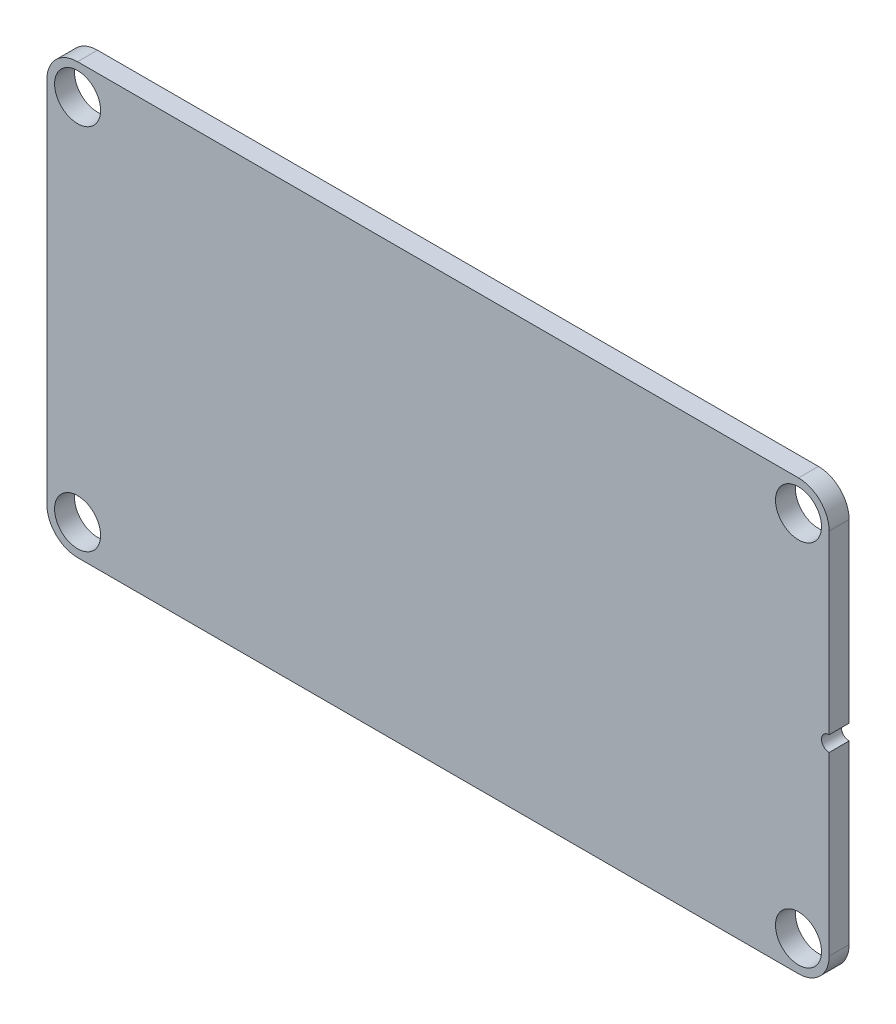
from build123d import *

# Parameters (mm, degrees)
SKETCH_1_W          = 51
SKETCH_1_H          = 28
EXTRUDE_1_DEPTH     = 1.3
SKETCH_2_R          = 1.5
CUT_EXTRUDE_1_DEPTH = 1.3
FILLET_1_R          = 2
FILLET_2_R          = 2
FILLET_3_R          = 2
FILLET_4_R          = 2
SKETCH_4_R          = 0.5
CUT_EXTRUDE_2_DEPTH = 8.8


with BuildPart() as part:
    # Эскиз1 → Бобышка-Вытянуть1 (new body)
    with BuildSketch(Plane.XY):
        Rectangle(SKETCH_1_W, SKETCH_1_H)
    extrude(amount=EXTRUDE_1_DEPTH)

    # Эскиз2 → Вырез-Вытянуть1 (cut)
    with BuildSketch(Plane.XY.offset(1.3)):
        with Locations((23.5, 12)):
            Circle(SKETCH_2_R)
        with Locations((23.5, -12)):
            Circle(SKETCH_2_R)
        with Locations((-23.5, -12)):
            Circle(SKETCH_2_R)
        with Locations((-23.5, 12)):
            Circle(SKETCH_2_R)
    extrude(amount=-CUT_EXTRUDE_1_DEPTH, mode=Mode.SUBTRACT)

    # Скругление1
    fillet_1_edges = [part.edges().sort_by_distance(p)[0] for p in [
        (25.5, 14, 0.65),
    ]]
    fillet(fillet_1_edges, radius=FILLET_1_R)

    # Скругление2
    fillet_2_edges = [part.edges().sort_by_distance(p)[0] for p in [
        (25.5, -14, 0.65),
    ]]
    fillet(fillet_2_edges, radius=FILLET_2_R)

    # Скругление3
    fillet_3_edges = [part.edges().sort_by_distance(p)[0] for p in [
        (-25.5, -14, 0.65),
    ]]
    fillet(fillet_3_edges, radius=FILLET_3_R)

    # Скругление4
    fillet_4_edges = [part.edges().sort_by_distance(p)[0] for p in [
        (-25.5, 14, 0.65),
    ]]
    fillet(fillet_4_edges, radius=FILLET_4_R)

    # Эскиз4 → Вырез-Вытянуть2 (cut)
    with BuildSketch(Plane.XY.offset(1.3)):
        with Locations((25.5, 0)):
            Circle(SKETCH_4_R)
    extrude(amount=-CUT_EXTRUDE_2_DEPTH, mode=Mode.SUBTRACT)


solid = part.part
